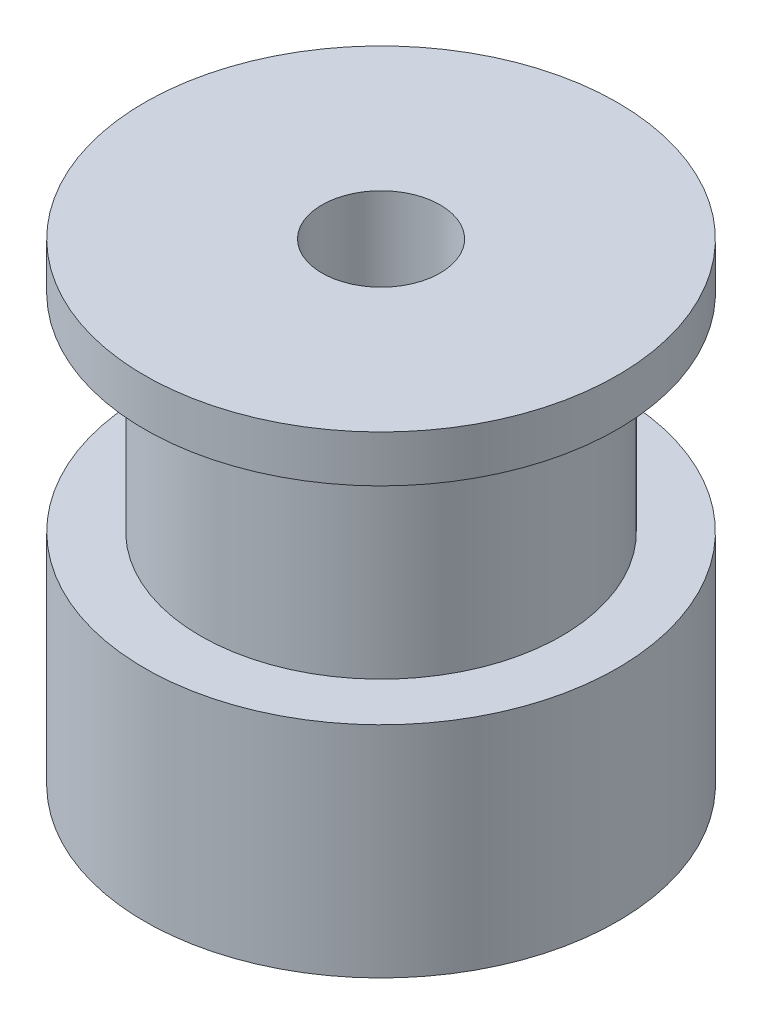
from build123d import *


with BuildPart() as part:
    # Sketch1 → Revolve1 (revolve)
    with BuildSketch(Plane.XY):
        Polygon((-2, 0), (-8, 0), (-8, 7.42), (-6.11, 7.42), (-6.11, 14.42), (-8, 14.42), (-8, 16), (-2, 16), align=None)
    revolve(axis=Axis((0, 0, 0), (0, 1, 0)))


solid = part.part
